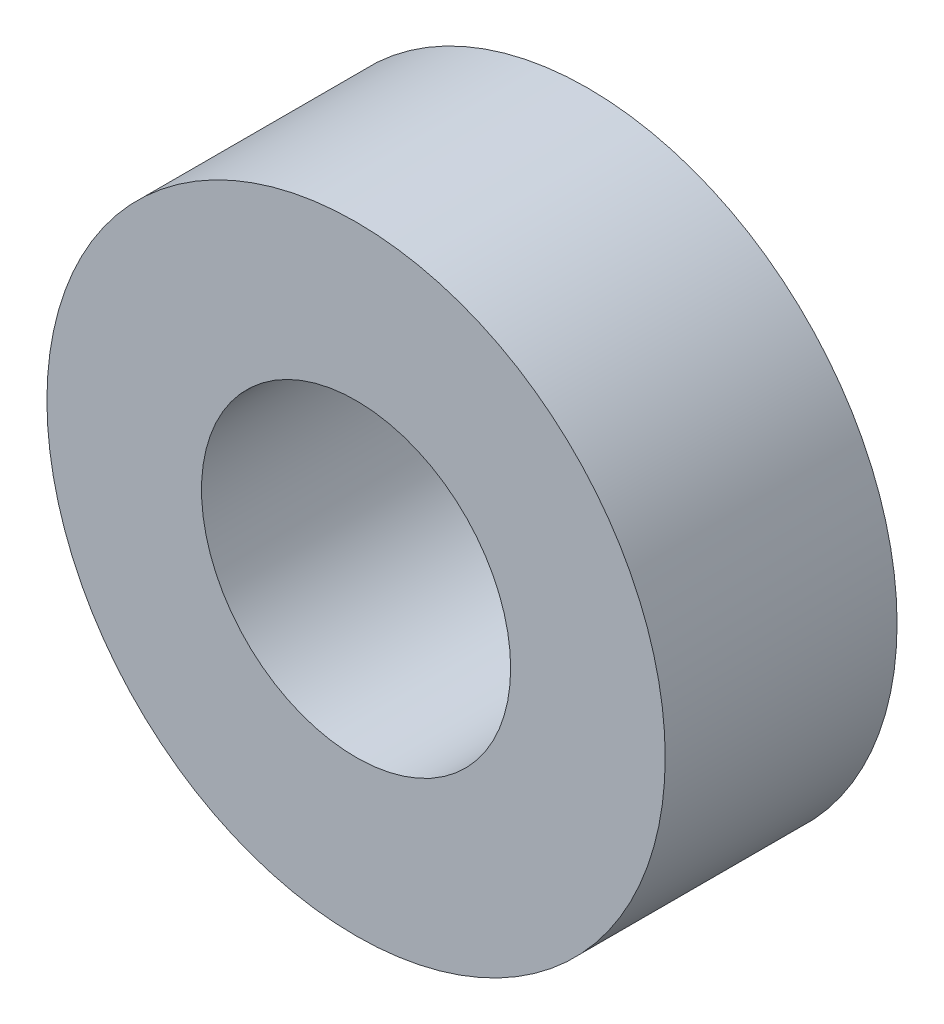
from build123d import *

# Parameters (mm, degrees)
SKETCH2_R           = 6.35
SKETCH2_R_2         = 3.175
BOSS_EXTRUDE1_DEPTH = 4.7625


with BuildPart() as part:
    # Sketch2 → Boss-Extrude1 (new body)
    with BuildSketch(Plane.XY.offset(4.7625)):
        with Locations((290.308718483, 659.279772728)):
            Circle(SKETCH2_R)
        with Locations((290.308718483, 659.279772728)):
            Circle(SKETCH2_R_2, mode=Mode.SUBTRACT)
    extrude(amount=BOSS_EXTRUDE1_DEPTH)


solid = part.part
